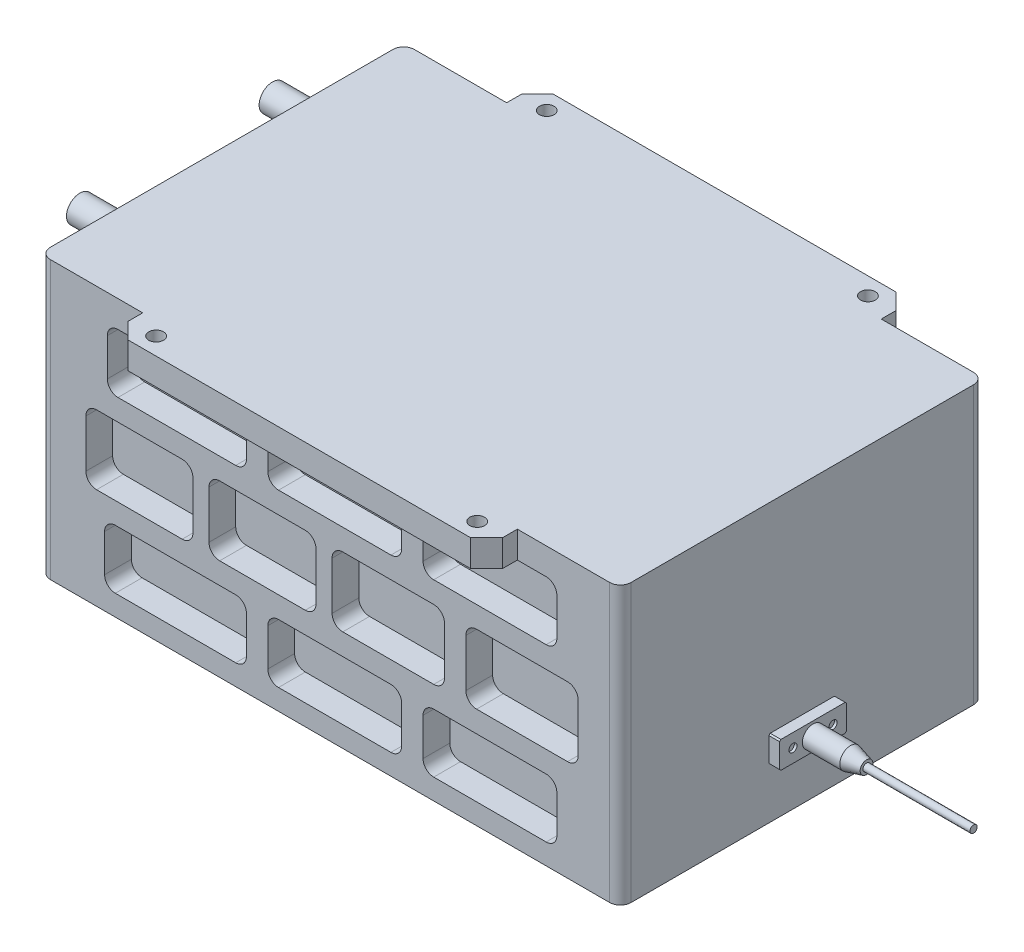
from build123d import *

# Parameters (mm, degrees)
SKETCH1_W           = 217
SKETCH1_H           = 136
BOSS_EXTRUDE1_DEPTH = 103.6
SKETCH2_W           = 140
SKETCH2_H           = 159
BOSS_EXTRUDE2_DEPTH = 10
SKETCH3_R           = 2.75
CUT_EXTRUDE1_DEPTH  = 10
SKETCH5_W           = 25
SKETCH5_H           = 10
BOSS_EXTRUDE3_DEPTH = 4
SKETCH6_R           = 4
BOSS_EXTRUDE4_DEPTH = 20
CHAMFER1_SIZE       = 6
CHAMFER1_SIZE2      = 1.607695155
SKETCH7_R           = 7.5
BOSS_EXTRUDE5_DEPTH = 2
SKETCH8_R           = 1.5
CUT_EXTRUDE2_DEPTH  = 1
CHAMFER2_SIZE       = 0.5
CHAMFER3_SIZE       = 6
SKETCH9_R           = 5
SKETCH9_R_2         = 4
BOSS_EXTRUDE6_DEPTH = 15
FILLET2_R           = 4
SKETCH11_W          = 40
SKETCH11_H          = 25.867142504
SKETCH11_W_2        = 53
SKETCH11_H_2        = 22
SKETCH11_W_3        = 42
SKETCH11_W_4        = 50
CUT_EXTRUDE4_DEPTH  = 10
FILLET3_R           = 4
FILLET4_R           = 4
SKETCH13_R          = 1.34767335
BOSS_EXTRUDE7_DEPTH = 40


with BuildPart() as part:
    # Sketch1 → Boss-Extrude1 (new body)
    with BuildSketch(Plane(origin=(0, 0, 0), x_dir=(1, 0, 0), z_dir=(0, 1, 0))):
        with Locations((-108.5, 68)):
            Rectangle(SKETCH1_W, SKETCH1_H)
    extrude(amount=BOSS_EXTRUDE1_DEPTH)

    # Sketch2 → Boss-Extrude2 (add)
    with BuildSketch(Plane(origin=(0, 103.6, 0), x_dir=(1, 0, 0), z_dir=(0, 1, 0))):
        with Locations((-108.5, 68)):
            Rectangle(SKETCH2_W, SKETCH2_H)
    extrude(amount=-BOSS_EXTRUDE2_DEPTH)

    # Sketch3 → Cut-Extrude1 (cut)
    with BuildSketch(Plane(origin=(0, 103.6, 0), x_dir=(1, 0, 0), z_dir=(0, 1, 0))):
        with Locations(Location((-168.5, 141, 0), (0, 0, 270))):  # turned: the seam where the file's is
            Circle(SKETCH3_R)
        with Locations(Location((-48.5, 141, 0), (0, 0, 270))):  # turned: the seam where the file's is
            Circle(SKETCH3_R)
        with Locations(Location((-168.5, -5, 0), (0, 0, 270))):  # turned: the seam where the file's is
            Circle(SKETCH3_R)
        with Locations(Location((-48.5, -5, 0), (0, 0, 270))):  # turned: the seam where the file's is
            Circle(SKETCH3_R)
    extrude(amount=-CUT_EXTRUDE1_DEPTH, mode=Mode.SUBTRACT)

    # Sketch5 → Boss-Extrude3 (add)
    with BuildSketch(Plane(origin=(0, 0, 0), x_dir=(0, 0, -1), z_dir=(1, 0, 0))):
        with Locations((68, 23.8)):
            Rectangle(SKETCH5_W, SKETCH5_H)
    extrude(amount=BOSS_EXTRUDE3_DEPTH)

    # Sketch6 → Boss-Extrude4 (add)
    with BuildSketch(Plane(origin=(4, 0, 0), x_dir=(0, 0, -1), z_dir=(1, 0, 0))):
        with Locations((68, 23.8)):
            Circle(SKETCH6_R)
    extrude(amount=BOSS_EXTRUDE4_DEPTH)

    # Chamfer1
    chamfer1_edges = [part.edges().sort_by_distance(p)[0] for p in [
        (24, 23.8, -64),
    ]]
    chamfer1_side = [part.faces().sort_by_distance(p)[0] for p in [
        (14, 23.8, -64),
    ]]
    chamfer(chamfer1_edges, length=CHAMFER1_SIZE, length2=CHAMFER1_SIZE2, reference=chamfer1_side[0])

    # Sketch7 → Boss-Extrude5 (add)
    with BuildSketch(Plane.ZY.offset(217)):
        with Locations(Location((-104, 93.6, 0), (0, 0, 180))):  # turned: the seam where the file's is
            Circle(SKETCH7_R)
        with Locations(Location((-32, 93.6, 0), (0, 0, 180))):  # turned: the seam where the file's is
            Circle(SKETCH7_R)
    extrude(amount=BOSS_EXTRUDE5_DEPTH)

    # Sketch8 → Cut-Extrude2 (cut)
    with BuildSketch(Plane(origin=(4, 0, 0), x_dir=(0, 0, -1), z_dir=(1, 0, 0))):
        with Locations((75.5, 23.8)):
            Circle(SKETCH8_R)
        with Locations((60.5, 23.8)):
            Circle(SKETCH8_R)
    extrude(amount=-CUT_EXTRUDE2_DEPTH, mode=Mode.SUBTRACT)

    # Chamfer2
    chamfer2_edges = [part.edges().sort_by_distance(p)[0] for p in [
        (2, 28.8, -55.5),
        (2, 18.8, -55.5),
        (2, 18.8, -80.5),
        (2, 28.8, -80.5),
    ]]
    chamfer(chamfer2_edges, length=CHAMFER2_SIZE)

    # Chamfer3
    chamfer3_edges = [part.edges().sort_by_distance(p)[0] for p in [
        (-178.5, 98.6, 11.5),
        (-38.5, 98.6, -147.5),
        (-178.5, 98.6, -147.5),
        (-38.5, 98.6, 11.5),
    ]]
    chamfer(chamfer3_edges, length=CHAMFER3_SIZE)

    # Sketch9 → Boss-Extrude6 (add)
    with BuildSketch(Plane.ZY.offset(219)):
        with Locations((-104, 93.6)):
            Circle(SKETCH9_R)
        with Locations((-104, 93.6)):
            Circle(SKETCH9_R_2, mode=Mode.SUBTRACT)
        with Locations((-32, 93.6)):
            Circle(SKETCH9_R)
        with Locations((-32, 93.6)):
            Circle(SKETCH9_R_2, mode=Mode.SUBTRACT)
    extrude(amount=BOSS_EXTRUDE6_DEPTH)

    # Fillet2
    fillet2_edges = [part.edges().sort_by_distance(p)[0] for p in [
        (0, 51.8, 0),
        (-217, 51.8, 0),
        (-217, 51.8, -136),
        (0, 51.8, -136),
    ]]
    fillet(fillet2_edges, radius=FILLET2_R)

    # Sketch11 → Cut-Extrude4 (cut)
    with BuildSketch(Plane(origin=(0, 0, -136), x_dir=(-1, 0, 0), z_dir=(0, 0, -1))):
        Polygon((38.5, 93.6), (73.74449782, 93.6), (73.74449782, 71.6), (23.74449782, 71.6), (23.74449782, 93.6), align=None)
        Polygon((178.5, 93.6), (191.74449782, 93.6), (191.74449782, 71.6), (139.74449782, 71.6), (139.74449782, 93.6), align=None)
        with Locations((179.74449782, 50.666428748)):
            Rectangle(SKETCH11_W, SKETCH11_H)
        with Locations((166.24449782, 18.732857496)):
            Rectangle(SKETCH11_W_2, SKETCH11_H_2)
        with Locations((133.74449782, 50.666428748)):
            Rectangle(SKETCH11_W, SKETCH11_H)
        with Locations((36.74449782, 50.666428748)):
            Rectangle(SKETCH11_W_3, SKETCH11_H)
        with Locations((48.74449782, 18.732857496)):
            Rectangle(SKETCH11_W_4, SKETCH11_H_2)
        with Locations((106.74449782, 82.6)):
            Rectangle(SKETCH11_W_4, SKETCH11_H_2)
        with Locations((86.74449782, 50.666428748)):
            Rectangle(SKETCH11_W_3, SKETCH11_H)
        with Locations((106.74449782, 18.732857496)):
            Rectangle(SKETCH11_W_4, SKETCH11_H_2)
    cut_extrude4 = extrude(amount=-CUT_EXTRUDE4_DEPTH, mode=Mode.SUBTRACT)

    # Fillet3
    fillet3_edges = [part.edges().sort_by_distance(p)[0] for p in [
        (-159.74449782, 63.6, -131),
        (-199.74449782, 63.6, -131),
        (-199.74449782, 37.732857496, -131),
        (-159.74449782, 37.732857496, -131),
        (-65.74449782, 63.6, -131),
        (-107.74449782, 63.6, -131),
        (-107.74449782, 37.732857496, -131),
        (-65.74449782, 37.732857496, -131),
        (-81.74449782, 93.6, -131),
        (-131.74449782, 93.6, -131),
        (-131.74449782, 71.6, -131),
        (-81.74449782, 71.6, -131),
        (-81.74449782, 7.732857496, -131),
        (-81.74449782, 29.732857496, -131),
        (-131.74449782, 29.732857496, -131),
        (-131.74449782, 7.732857496, -131),
        (-139.74449782, 29.732857496, -131),
        (-192.74449782, 29.732857496, -131),
        (-192.74449782, 7.732857496, -131),
        (-139.74449782, 7.732857496, -131),
        (-23.74449782, 7.732857496, -131),
        (-23.74449782, 29.732857496, -131),
        (-73.74449782, 29.732857496, -131),
        (-73.74449782, 7.732857496, -131),
        (-57.74449782, 63.6, -131),
        (-57.74449782, 37.732857496, -131),
        (-15.74449782, 37.732857496, -131),
        (-15.74449782, 63.6, -131),
        (-139.74449782, 93.6, -131),
        (-191.74449782, 93.6, -131),
        (-191.74449782, 71.6, -131),
        (-139.74449782, 71.6, -131),
        (-113.74449782, 63.6, -131),
        (-153.74449782, 63.6, -131),
        (-153.74449782, 37.732857496, -131),
        (-113.74449782, 37.732857496, -131),
        (-23.74449782, 93.6, -131),
        (-73.74449782, 93.6, -131),
        (-73.74449782, 71.6, -131),
        (-23.74449782, 71.6, -131),
    ]]
    fillet(fillet3_edges, radius=FILLET3_R)

    # Mirror1: Cut-Extrude4 across plane
    add(cut_extrude4.mirror(Plane(origin=(0, 0, -68), x_dir=(1, 0, 0), z_dir=(0, 0, -1))), mode=Mode.SUBTRACT)

    # Fillet4
    fillet4_edges = [part.edges().sort_by_distance(p)[0] for p in [
        (-199.74449782, 63.6, -5),
        (-159.74449782, 63.6, -5),
        (-159.74449782, 37.732857496, -5),
        (-199.74449782, 37.732857496, -5),
        (-107.74449782, 63.6, -5),
        (-65.74449782, 63.6, -5),
        (-65.74449782, 37.732857496, -5),
        (-107.74449782, 37.732857496, -5),
        (-131.74449782, 93.6, -5),
        (-81.74449782, 93.6, -5),
        (-81.74449782, 71.6, -5),
        (-131.74449782, 71.6, -5),
        (-81.74449782, 29.732857496, -5),
        (-81.74449782, 7.732857496, -5),
        (-131.74449782, 7.732857496, -5),
        (-131.74449782, 29.732857496, -5),
        (-192.74449782, 29.732857496, -5),
        (-139.74449782, 29.732857496, -5),
        (-139.74449782, 7.732857496, -5),
        (-192.74449782, 7.732857496, -5),
        (-23.74449782, 29.732857496, -5),
        (-23.74449782, 7.732857496, -5),
        (-73.74449782, 7.732857496, -5),
        (-73.74449782, 29.732857496, -5),
        (-57.74449782, 37.732857496, -5),
        (-57.74449782, 63.6, -5),
        (-15.74449782, 63.6, -5),
        (-15.74449782, 37.732857496, -5),
        (-139.74449782, 93.6, -5),
        (-139.74449782, 71.6, -5),
        (-191.74449782, 71.6, -5),
        (-191.74449782, 93.6, -5),
        (-153.74449782, 63.6, -5),
        (-113.74449782, 63.6, -5),
        (-113.74449782, 37.732857496, -5),
        (-153.74449782, 37.732857496, -5),
        (-23.74449782, 93.6, -5),
        (-23.74449782, 71.6, -5),
        (-73.74449782, 71.6, -5),
        (-73.74449782, 93.6, -5),
    ]]
    fillet(fillet4_edges, radius=FILLET4_R)

    # Sketch13 → Boss-Extrude7 (add)
    with BuildSketch(Plane(origin=(24, 0, 0), x_dir=(0, 0, -1), z_dir=(1, 0, 0))):
        with Locations((68, 23.8)):
            Circle(SKETCH13_R)
    extrude(amount=BOSS_EXTRUDE7_DEPTH)


solid = part.part
